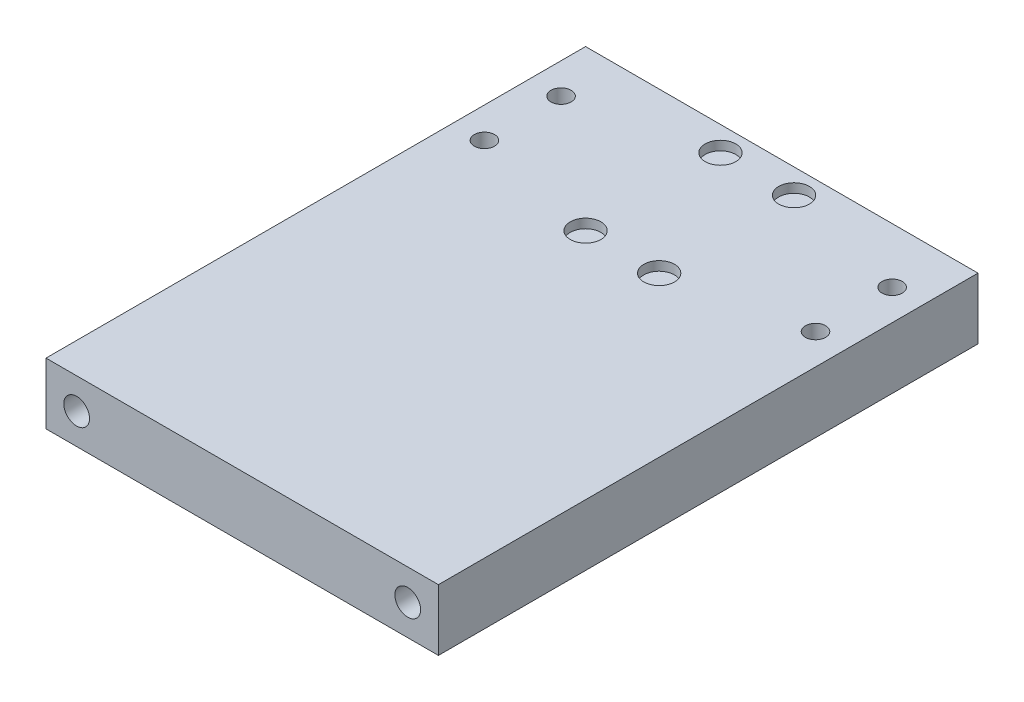
from build123d import *

# Parameters (mm, degrees)
BOSS_EXTRUDE1_DEPTH     = 64
SKETCH3_R               = 2.25
CUT_EXTRUDE1_DEPTH      = 10
LPATTERN1_COUNT         = 2
LPATTERN1_PITCH         = 30
LPATTERN1_COUNT_DIR2    = 2
LPATTERN1_PITCH_DIR2    = 20
CUT_EXTRUDE3_DEPTH      = 10
SKETCH6_R               = 2.5
CUT_EXTRUDE4_DEPTH      = 1.5
LPATTERN3_COUNT         = 2
LPATTERN3_PITCH         = 12
LPATTERN3_COUNT_DIR2    = 2
LPATTERN3_PITCH_DIR2    = 22
SKETCH9_W               = 23.325235192
SKETCH9_H               = 64.951426749
CUT_EXTRUDE7_DEPTH      = 33
CUT_EXTRUDE7_DEPTH_BACK = 33
M5_TAPPED_HOLE1_D       = 4.2
M5_TAPPED_HOLE1_DEPTH   = 18
M5_TAPPED_HOLE1_TIP     = 1.2618073
M4_TAPPED_HOLE1_D       = 3.3


with BuildPart() as part:
    # Sketch1 → Boss-Extrude1 (new body)
    with BuildSketch(Plane(origin=(0, 0, 0), x_dir=(0, 0, -1), z_dir=(1, 0, 0))):
        Polygon((0, 60.5), (0, 0), (98, 0), (98, 10), (10, 10), (10, 60.5), align=None)
    extrude(amount=BOSS_EXTRUDE1_DEPTH)

    # Sketch3 → Cut-Extrude1 (cut)
    with BuildSketch(Plane(origin=(0, 0, -10), x_dir=(-1, 0, 0), z_dir=(0, 0, -1))):
        with Locations(Location((-47, 53.5, 0), (0, 0, 90))):  # turned: the seam where the file's is
            Circle(SKETCH3_R)
    cut_extrude1 = extrude(amount=-CUT_EXTRUDE1_DEPTH, mode=Mode.SUBTRACT)

    # LPattern1: Cut-Extrude1 2 × 2
    with Locations(*[(-i * LPATTERN1_PITCH, -j * LPATTERN1_PITCH_DIR2, 0) for i in range(LPATTERN1_COUNT) for j in range(LPATTERN1_COUNT_DIR2) if (i, j) != (0, 0)]):
        add(cut_extrude1, mode=Mode.SUBTRACT)

    # Sketch5 → Cut-Extrude3 (cut)
    with BuildSketch(Plane(origin=(0, 0, -10), x_dir=(-1, 0, 0), z_dir=(0, 0, -1))):
        with BuildLine():
            Line((-29.5, 55.3), (-29.5, 30.3))
            ThreePointArc((-29.5, 30.3), (-32, 27.8), (-34.5, 30.3))
            Line((-34.5, 30.3), (-34.5, 55.3))
            ThreePointArc((-34.5, 55.3), (-32, 57.8), (-29.5, 55.3))
        make_face()
    extrude(amount=-CUT_EXTRUDE3_DEPTH, mode=Mode.SUBTRACT)

    # Sketch6 → Cut-Extrude4 (cut)
    with BuildSketch(Plane(origin=(0, 10, 0), x_dir=(1, 0, 0), z_dir=(0, 1, 0))):
        with Locations(Location((38, 94, 0), (0, 0, 270))):  # turned: the seam where the file's is
            Circle(SKETCH6_R)
    cut_extrude4 = extrude(amount=-CUT_EXTRUDE4_DEPTH, mode=Mode.SUBTRACT)

    # LPattern3: Cut-Extrude4 2 × 2
    with Locations(*[(-i * LPATTERN3_PITCH, 0, j * LPATTERN3_PITCH_DIR2) for i in range(LPATTERN3_COUNT) for j in range(LPATTERN3_COUNT_DIR2) if (i, j) != (0, 0)]):
        add(cut_extrude4, mode=Mode.SUBTRACT)

    # Sketch9 → Cut-Extrude7 (cut, two sides)
    with BuildSketch(Plane.ZY.offset(-32)) as cut_extrude7_sk:
        with Locations((1.662617596, 28.024286626)):
            Rectangle(SKETCH9_W, SKETCH9_H)
    extrude(amount=CUT_EXTRUDE7_DEPTH, mode=Mode.SUBTRACT)
    extrude(cut_extrude7_sk.sketch, amount=-CUT_EXTRUDE7_DEPTH_BACK, mode=Mode.SUBTRACT)

    # M5 Tapped Hole1
    with Locations(Plane.XY.offset(-10)):
        with Locations((59, 5), (5, 5)):
            Hole(M5_TAPPED_HOLE1_D / 2, depth=M5_TAPPED_HOLE1_DEPTH)
            with Locations((0, 0, -(M5_TAPPED_HOLE1_DEPTH + M5_TAPPED_HOLE1_TIP / 2))):  # 118° drill point
                Cone(0, M5_TAPPED_HOLE1_D / 2, M5_TAPPED_HOLE1_TIP, mode=Mode.SUBTRACT)

    # M4 Tapped Hole1 (through all)
    with Locations(Plane(origin=(0, 10, 0), x_dir=(1, 0, 0), z_dir=(0, 1, 0))):
        with Locations((59, 89), (59, 76.5), (5, 76.5), (5, 89)):
            Hole(M4_TAPPED_HOLE1_D / 2)


solid = part.part
